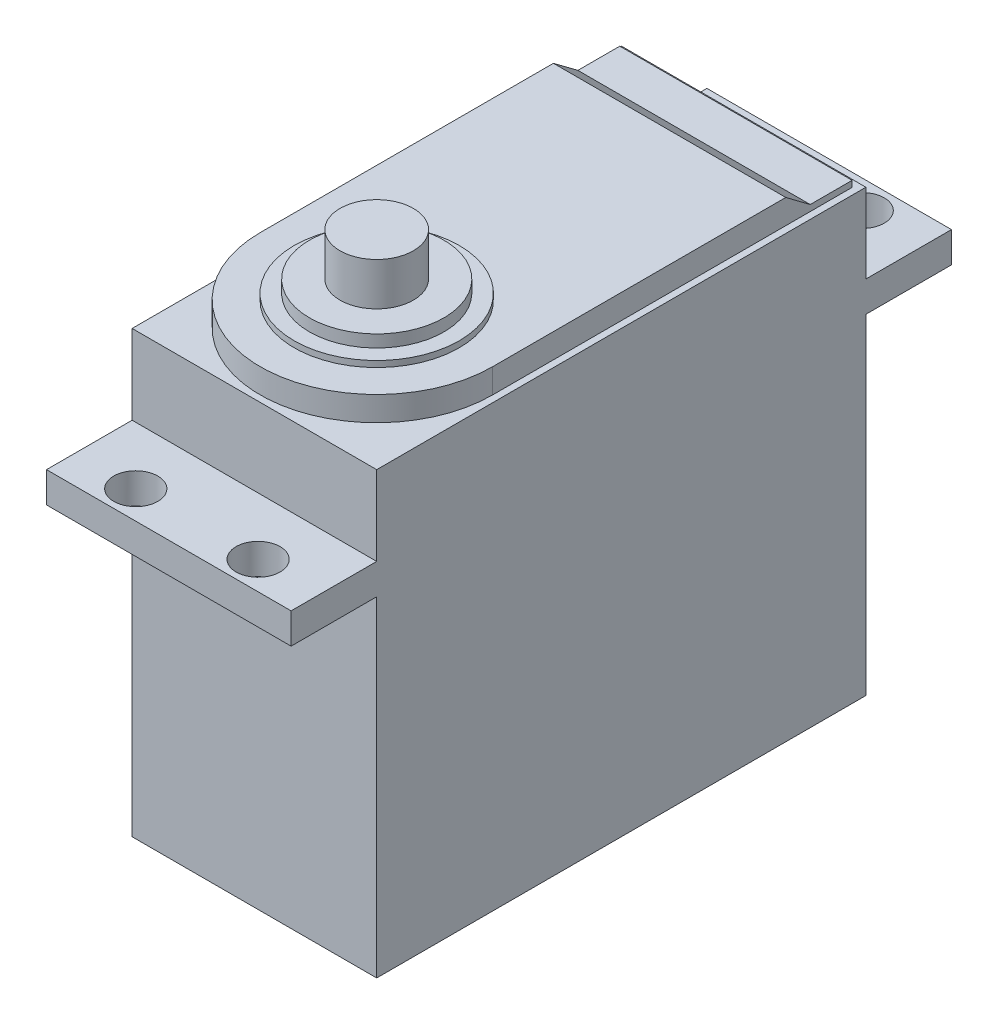
from build123d import *

# Parameters (mm, degrees)
SKETCH1_W           = 20
SKETCH1_H           = 38
BOSS_EXTRUDE1_DEPTH = 40
SKETCH2_W           = 7
SKETCH2_H           = 2.5
BOSS_EXTRUDE2_DEPTH = 20
CUT_EXTRUDE1_DEPTH  = 40
SKETCH4_R           = 1.8
CUT_EXTRUDE2_DEPTH  = 10
SKETCH5_W           = 20
SKETCH5_H           = 40
CUT_EXTRUDE3_DEPTH  = 2
SKETCH6_R           = 6.75
SKETCH6_R_2         = 5.5
BOSS_EXTRUDE3_DEPTH = 0.5
SKETCH6_4_R         = 5.5
SKETCH6_4_R_2       = 3
BOSS_EXTRUDE4_DEPTH = 1.5
SKETCH6_5_R         = 3
BOSS_EXTRUDE5_DEPTH = 5


with BuildPart() as part:
    # Sketch1 → Boss-Extrude1 (new body)
    with BuildSketch(Plane.XY):
        with Locations((10, 19)):
            Rectangle(SKETCH1_W, SKETCH1_H)
    extrude(amount=BOSS_EXTRUDE1_DEPTH)

    # Sketch2 → Boss-Extrude2 (add)
    with BuildSketch(Plane.ZY):
        with Locations((-3.5, 28.25)):
            Rectangle(SKETCH2_W, SKETCH2_H)
        with Locations((43.5, 28.25)):
            Rectangle(SKETCH2_W, SKETCH2_H)
    extrude(amount=-BOSS_EXTRUDE2_DEPTH)

    # Sketch3 → Cut-Extrude1 (cut)
    with BuildSketch(Plane.ZY):
        Polygon((6, 38), (4, 36.5), (0, 36.5), (0, 38), align=None)
    extrude(amount=-CUT_EXTRUDE1_DEPTH, mode=Mode.SUBTRACT)

    # Sketch4 → Cut-Extrude2 (cut)
    with BuildSketch(Plane(origin=(0, 29.5, 0), x_dir=(1, 0, 0), z_dir=(0, 1, 0))):
        with Locations((15, -44.7)):
            Circle(SKETCH4_R)
        with Locations((5, -44.7)):
            Circle(SKETCH4_R)
        with Locations((15, 4.7)):
            Circle(SKETCH4_R)
        with Locations((5, 4.7)):
            Circle(SKETCH4_R)
    extrude(amount=-CUT_EXTRUDE2_DEPTH, mode=Mode.SUBTRACT)

    # Sketch5 → Cut-Extrude3 (cut)
    with BuildSketch(Plane(origin=(0, 38, 0), x_dir=(1, 0, 0), z_dir=(0, 1, 0))):
        with Locations((10, -20)):
            Rectangle(SKETCH5_W, SKETCH5_H)
        with BuildLine():
            Line((19.449743203, -29.975974241), (19.449743203, -0.575747889))
            Line((19.449743203, -0.575747889), (0.449743203, -0.575747889))
            Line((0.449743203, -0.575747889), (0.449743203, -29.975974241))
            ThreePointArc((0.449743203, -29.975974241), (9.949743203, -39.475974241), (19.449743203, -29.975974241))
        make_face(mode=Mode.SUBTRACT)
    extrude(amount=-CUT_EXTRUDE3_DEPTH, mode=Mode.SUBTRACT)

    # Sketch6 → Boss-Extrude3 (add)
    with BuildSketch(Plane(origin=(0, 38, 0), x_dir=(1, 0, 0), z_dir=(0, 1, 0))):
        with Locations((10, -30)):
            Circle(SKETCH6_R)
        with Locations((10, -30)):
            Circle(SKETCH6_R_2, mode=Mode.SUBTRACT)
    extrude(amount=BOSS_EXTRUDE3_DEPTH)

    # Sketch6_4 → Boss-Extrude4 (add)
    with BuildSketch(Plane(origin=(0, 38, 0), x_dir=(1, 0, 0), z_dir=(0, 1, 0))):
        with Locations((10, -30)):
            Circle(SKETCH6_4_R)
        with Locations((10, -30)):
            Circle(SKETCH6_4_R_2, mode=Mode.SUBTRACT)
    extrude(amount=BOSS_EXTRUDE4_DEPTH)

    # Sketch6_5 → Boss-Extrude5 (add)
    with BuildSketch(Plane(origin=(0, 38, 0), x_dir=(1, 0, 0), z_dir=(0, 1, 0))):
        with Locations((10, -30)):
            Circle(SKETCH6_5_R)
    extrude(amount=BOSS_EXTRUDE5_DEPTH)


solid = part.part
